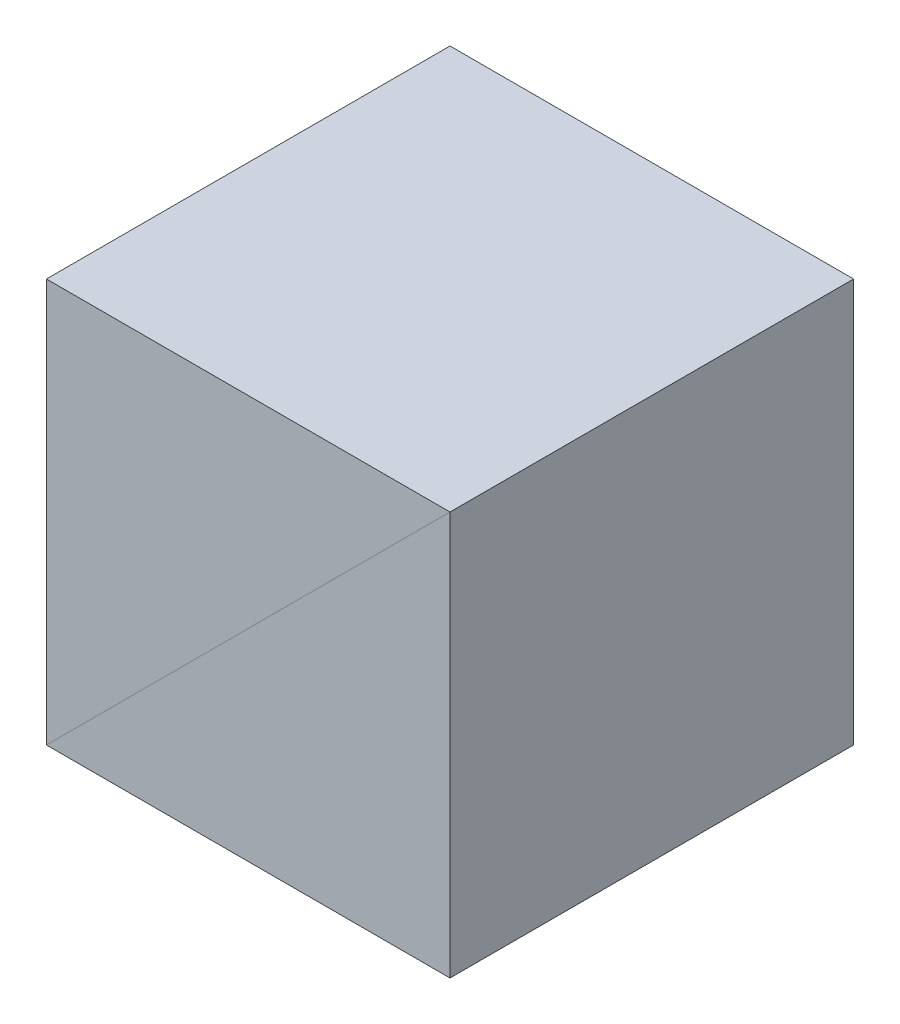
from build123d import *

# Parameters (mm, degrees)
EXTRUDE_1_DEPTH = 12.7


with BuildPart() as part:
    # 草图1 → 凸台-拉伸1 (new body, symmetric)
    with BuildSketch(Plane.XY):
        Polygon((-12.7, -12.7), (12.7, -12.7), (12.7, 12.7), align=None)
    extrude(amount=EXTRUDE_1_DEPTH, both=True)


with BuildPart() as body_2:
    # 镜向2: mirrored copy
    add(part.part.mirror(Plane(origin=(12.7, 12.7, 12.7), x_dir=(0, 0, 1), z_dir=(0.707106781, -0.707106781, 0))))


solid = Compound([part.part, body_2.part])
